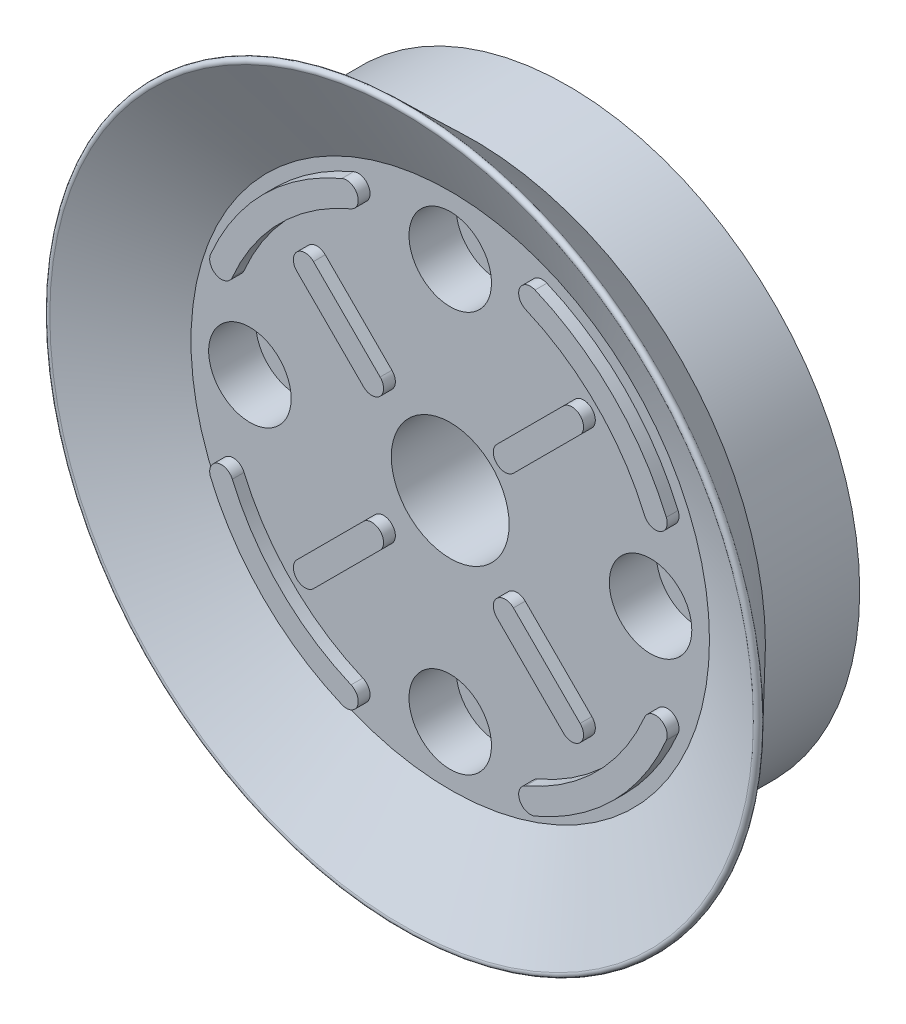
from build123d import *

# Parameters (mm, degrees)
SKETCH_1_R                = 24.75
EXTRUDE_1_DEPTH           = 8
FILLET_1_R                = 0.3
SKETCH_3_R                = 5
CUT_EXTRUDE_1_DEPTH       = 5.166230823
CUT_EXTRUDE_1_DEPTH_BACK  = 11
HOLE_WIZARD_1_D           = 4
HOLE_WIZARD_1_DEPTH       = 100
HOLE_WIZARD_1_CBORE_D     = 7
HOLE_WIZARD_1_CBORE_DEPTH = 4
PATTERN_CIRCULAR_1_COUNT  = 4
EXTRUDE_1_2_DEPTH         = 1
EXTRUDE_3_DEPTH           = 1
PATTERN_CIRCULAR_2_COUNT  = 4


with BuildPart() as part:
    # 草图1 → Extrude 1 (new body)
    with BuildSketch(Plane.XY):
        Circle(SKETCH_1_R)
    extrude(amount=EXTRUDE_1_DEPTH)

    # 草图2 → 旋转1 (revolve)
    with BuildSketch(Plane(origin=(0, 0, 0), x_dir=(1, 0, 0), z_dir=(0, 1, 0))):
        Polygon((-24.75, -8), (-31.5, -15), (-22, -10), (0, -10), (0, -8), align=None)
    revolve(axis=Axis((0, 0, 10), (0, 0, -1)))

    # 圆角1
    fillet_1_edges = [part.edges().sort_by_distance(p)[0] for p in [
        (31.5, 0, 15),
    ]]
    fillet(fillet_1_edges, radius=FILLET_1_R)

    # 草图3 → 切除-拉伸1 (cut, two sides)
    with BuildSketch(Plane.XY.offset(10)) as cut_extrude_1_sk:
        Circle(SKETCH_3_R)
    extrude(amount=CUT_EXTRUDE_1_DEPTH, mode=Mode.SUBTRACT)
    extrude(cut_extrude_1_sk.sketch, amount=-CUT_EXTRUDE_1_DEPTH_BACK, mode=Mode.SUBTRACT)

    # 孔1
    with Locations(Plane.XY.offset(10)):
        with Locations((0, 17)):
            hole_wizard_1 = CounterBoreHole(HOLE_WIZARD_1_D / 2, HOLE_WIZARD_1_CBORE_D / 2, HOLE_WIZARD_1_CBORE_DEPTH, depth=HOLE_WIZARD_1_DEPTH)

    # 阵列(圆周)1: 孔1 ×4 about axis
    pattern_circular_1_axis = Axis((0, 0, 0), (0, 0, 1))
    for i in range(1, PATTERN_CIRCULAR_1_COUNT):
        add(hole_wizard_1.rotate(pattern_circular_1_axis, i * 360 / PATTERN_CIRCULAR_1_COUNT), mode=Mode.SUBTRACT)

    # 草图6 → Extrude 1 2 (add)
    with BuildSketch(Plane.XY.offset(10)):
        with BuildLine():
            ThreePointArc((-8.19715023, 19.334082034), (-14.849242405, 14.849242405), (-19.334082034, 8.19715023))
            ThreePointArc((-19.334082034, 8.19715023), (-18.803751948, 6.88613917), (-17.492740888, 7.416469256))
            ThreePointArc((-17.492740888, 7.416469256), (-13.435028843, 13.435028843), (-7.416469256, 17.492740888))
            ThreePointArc((-7.416469256, 17.492740888), (-6.88613917, 18.803751948), (-8.19715023, 19.334082034))
        make_face()
    extrude_1_2 = extrude(amount=EXTRUDE_1_2_DEPTH)

    # 草图7 → 凸台-拉伸3 (add)
    with BuildSketch(Plane.XY.offset(10)):
        with BuildLine():
            Line((-10.606601718, 12.02081528), (-4.949747468, 6.363961031))
            ThreePointArc((-4.949747468, 6.363961031), (-4.949747468, 4.949747468), (-6.363961031, 4.949747468))
            Line((-6.363961031, 4.949747468), (-12.02081528, 10.606601718))
            ThreePointArc((-12.02081528, 10.606601718), (-12.02081528, 12.02081528), (-10.606601718, 12.02081528))
        make_face()
    extrude_3 = extrude(amount=EXTRUDE_3_DEPTH)

    # 阵列(圆周)2: Extrude 1 2, 凸台-拉伸3 ×4 about axis
    pattern_circular_2_axis = Axis((0, 0, 0), (0, 0, 1))
    for i in range(1, PATTERN_CIRCULAR_2_COUNT):
        add(extrude_1_2.rotate(pattern_circular_2_axis, i * 360 / PATTERN_CIRCULAR_2_COUNT))
        add(extrude_3.rotate(pattern_circular_2_axis, i * 360 / PATTERN_CIRCULAR_2_COUNT))


solid = part.part
